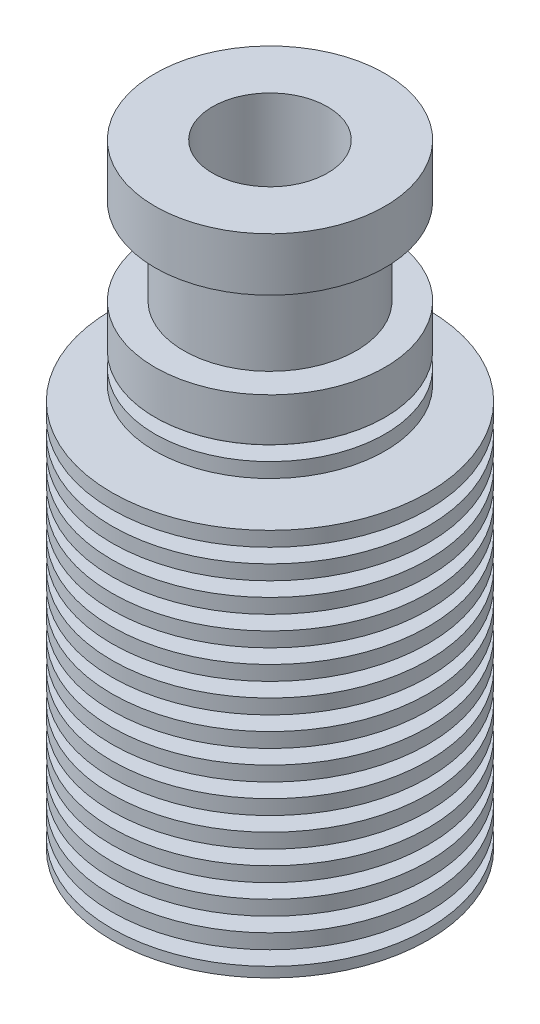
from build123d import *


with BuildPart() as part:
    # Croquis1 → Revolución2 (revolve)
    with BuildSketch(Plane.XY):
        Polygon((8, 42.7), (4, 42.7), (4, 36.2), (2.1, 34.605710701), (2.1, 15.427573211), (3, 15.1), (3, 0), (11, 0), (11, 30), (8, 30), (8, 33), (6, 33), (6, 39), (8, 39), align=None)
    revolve(axis=Axis((0, 0, 0), (0, 1, 0)))

    # Croquis2 → Cortar-Revolución1 (revolve, cut)
    with BuildSketch(Plane.XY):
        Polygon((6.561668068, 0.7), (11, 0.7), (11, 1.7), (6.474179405, 1.7), align=None)
        Polygon((6.297452304, 3.72), (6.384940968, 2.72), (11, 2.72), (11, 3.72), align=None)
        Polygon((6.120725204, 5.74), (6.208213867, 4.74), (11, 4.74), (11, 5.74), align=None)
        Polygon((5.943998104, 7.76), (6.031486767, 6.76), (11, 6.76), (11, 7.76), align=None)
        Polygon((5.767271003, 9.78), (5.854759667, 8.78), (11, 8.78), (11, 9.78), align=None)
        Polygon((5.590543903, 11.8), (5.678032566, 10.8), (11, 10.8), (11, 11.8), align=None)
        Polygon((5.413816803, 13.82), (5.501305466, 12.82), (11, 12.82), (11, 13.82), align=None)
        Polygon((5.237089702, 15.84), (5.324578366, 14.84), (11, 14.84), (11, 15.84), align=None)
        Polygon((5.060362602, 17.86), (5.147851265, 16.86), (11, 16.86), (11, 17.86), align=None)
        Polygon((4.883635502, 19.88), (4.971124165, 18.88), (11, 18.88), (11, 19.88), align=None)
        Polygon((4.706908401, 21.9), (4.794397065, 20.9), (11, 20.9), (11, 21.9), align=None)
        Polygon((4.530181301, 23.92), (4.617669964, 22.92), (11, 22.92), (11, 23.92), align=None)
        Polygon((4.353454201, 25.94), (4.440942864, 24.94), (11, 24.94), (11, 25.94), align=None)
        Polygon((4.1767271, 27.96), (4.264215764, 26.96), (11, 26.96), (11, 29.98), (4, 29.98), (4.087488664, 28.98), (8, 28.98), (8, 27.96), align=None)
    revolve(axis=Axis((0, 0, 0), (0, 1, 0)), mode=Mode.SUBTRACT)

    # Croquis3 → Cortar-Revolución4 (revolve, cut)
    with BuildSketch(Plane.XY):
        Polygon((10.994525772, 30), (11.094314794, 30), (11.094314794, 29.98), (7.992627906, 29.98), (7.992627906, 30), align=None)
    revolve(axis=Axis((0, 0, 0), (0, 1, 0)), mode=Mode.SUBTRACT)


solid = part.part
